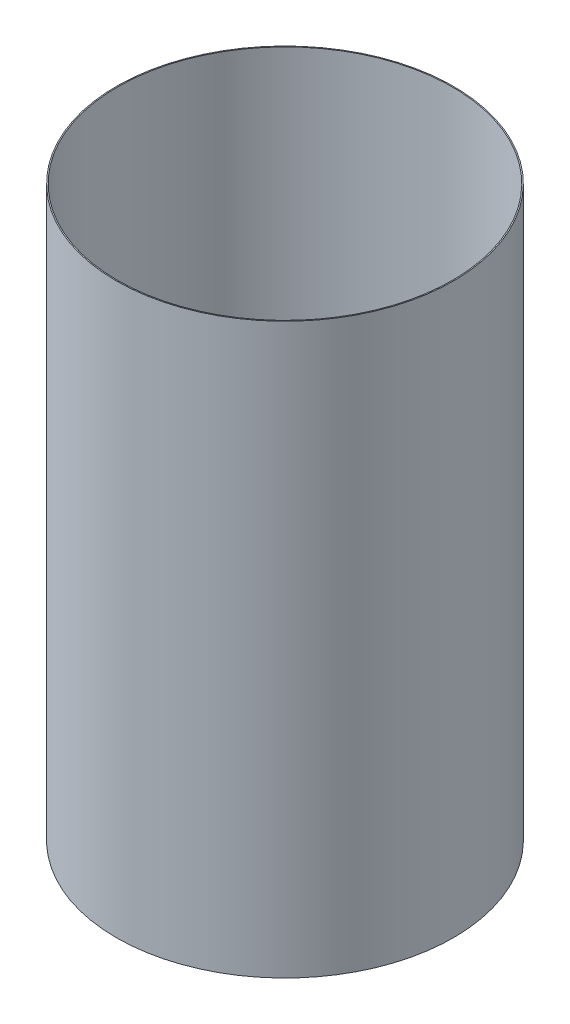
from build123d import *

# Parameters (mm, degrees)
SKETCH1_W = 0.254
SKETCH1_H = 133.35


with BuildPart() as part:
    # Sketch1 → Revolve-Thin1 (revolve)
    with BuildSketch(Plane.XY):
        with Locations((-39.3954, -135.67819341)):
            Rectangle(SKETCH1_W, SKETCH1_H)
    revolve(axis=Axis((0, 55, 0), (0, -1, 0)))


solid = part.part
